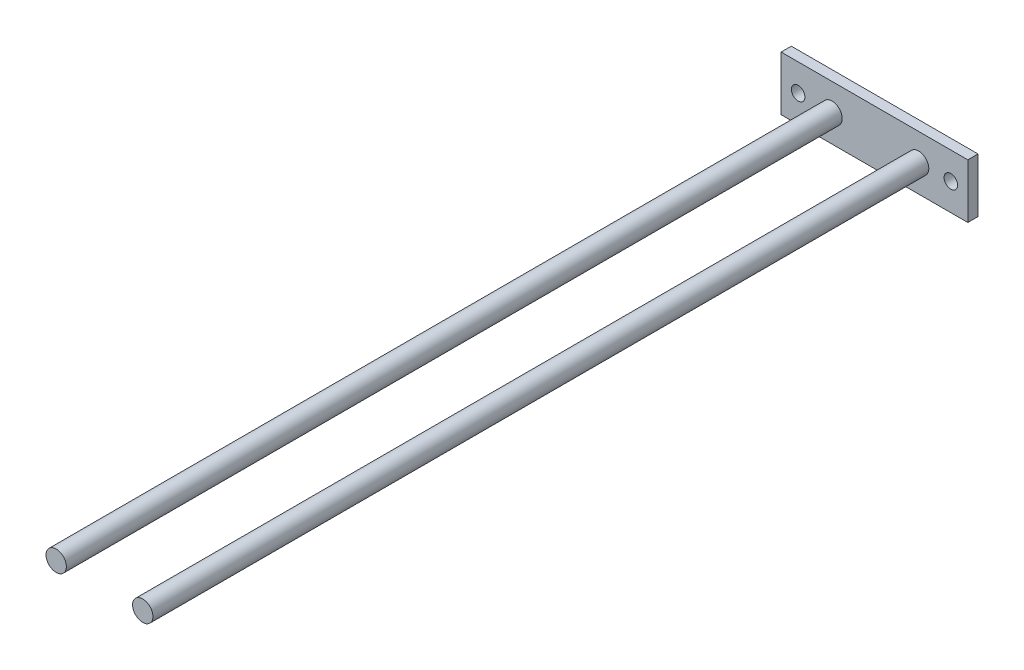
from build123d import *

# Parameters (mm, degrees)
SKETCH1_W           = 55
SKETCH1_H           = 16
SKETCH1_R           = 2
BOSS_EXTRUDE1_DEPTH = 3
SKETCH3_R           = 3
BOSS_EXTRUDE2_DEPTH = 228.6


with BuildPart() as part:
    # Sketch1 → Boss-Extrude1 (new body)
    with BuildSketch(Plane.XY):
        Rectangle(SKETCH1_W, SKETCH1_H)
        with Locations((-22.5, 0)):
            Circle(SKETCH1_R, mode=Mode.SUBTRACT)
        with Locations((22.5, 0)):
            Circle(SKETCH1_R, mode=Mode.SUBTRACT)
    extrude(amount=BOSS_EXTRUDE1_DEPTH)

    # Sketch3 → Boss-Extrude2 (add)
    with BuildSketch(Plane.XY.offset(3)):
        with Locations((-12.5, 0)):
            Circle(SKETCH3_R)
        with Locations((13, 0)):
            Circle(SKETCH3_R)
    extrude(amount=BOSS_EXTRUDE2_DEPTH)


solid = part.part
